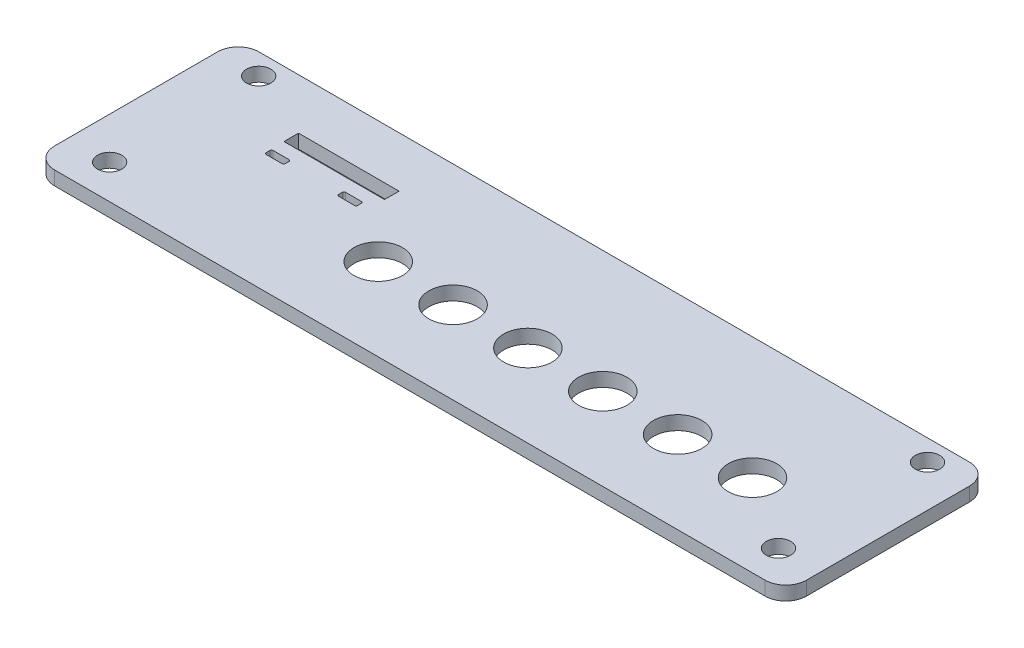
from build123d import *

# Parameters (mm, degrees)
SKETCH1_W           = 108.5
SKETCH1_H           = 29.5
BOSS_EXTRUDE1_DEPTH = 2
SKETCH2_R           = 1.75
CUT_EXTRUDE1_DEPTH  = 3
FILLET1_R           = 3
SKETCH5_R           = 3.5
SKETCH5_W           = 14.5
SKETCH5_H           = 2.1
SKETCH5_W_2         = 2.75
SKETCH5_H_2         = 1
CUT_EXTRUDE2_DEPTH  = 3
FILLET2_R           = 0.2


with BuildPart() as part:
    # Sketch1 → Boss-Extrude1 (new body)
    with BuildSketch(Plane(origin=(0, 0, 0), x_dir=(1, 0, 0), z_dir=(0, 1, 0))):
        with Locations((54.25, 14.75)):
            Rectangle(SKETCH1_W, SKETCH1_H)
    extrude(amount=BOSS_EXTRUDE1_DEPTH)

    # Sketch2 → Cut-Extrude1 (cut, through all)
    with BuildSketch(Plane(origin=(0, 2, 0), x_dir=(1, 0, 0), z_dir=(0, 1, 0))):
        with Locations((6, 26.45)):
            Circle(SKETCH2_R)
        with Locations((6, 4.95)):
            Circle(SKETCH2_R)
        with Locations((102.5, 4.95)):
            Circle(SKETCH2_R)
        with Locations((102.5, 26.45)):
            Circle(SKETCH2_R)
    extrude(amount=-CUT_EXTRUDE1_DEPTH, mode=Mode.SUBTRACT)

    # Fillet1
    fillet1_edges = [part.edges().sort_by_distance(p)[0] for p in [
        (0, 1, -29.5),
        (108.5, 1, -29.5),
        (108.5, 1, 0),
        (0, 1, 0),
    ]]
    fillet(fillet1_edges, radius=FILLET1_R)

    # Sketch5 → Cut-Extrude2 (cut, through all)
    with BuildSketch(Plane(origin=(0, 2, 0), x_dir=(1, 0, 0), z_dir=(0, 1, 0))):
        with Locations((91.8, 11.9)):
            Circle(SKETCH5_R)
        with Locations((81, 11.9)):
            Circle(SKETCH5_R)
        with Locations((70.2, 11.9)):
            Circle(SKETCH5_R)
        with Locations((59.4, 11.9)):
            Circle(SKETCH5_R)
        with Locations((48.6, 11.9)):
            Circle(SKETCH5_R)
        with Locations((37.8, 11.9)):
            Circle(SKETCH5_R)
        with Locations((23.25, 21.15)):
            Rectangle(SKETCH5_W, SKETCH5_H)
        with Locations((17.475, 17.7)):
            Rectangle(SKETCH5_W_2, SKETCH5_H_2)
        with Locations((27.925, 17.7)):
            Rectangle(SKETCH5_W_2, SKETCH5_H_2)
    extrude(amount=-CUT_EXTRUDE2_DEPTH, mode=Mode.SUBTRACT)

    # Fillet2
    fillet2_edges = [part.edges().sort_by_distance(p)[0] for p in [
        (26.55, 1, -17.2),
        (26.55, 1, -18.2),
        (29.3, 1, -18.2),
        (29.3, 1, -17.2),
        (18.85, 1, -18.2),
        (18.85, 1, -17.2),
        (16.1, 1, -17.2),
        (16.1, 1, -18.2),
    ]]
    fillet(fillet2_edges, radius=FILLET2_R)


solid = part.part
